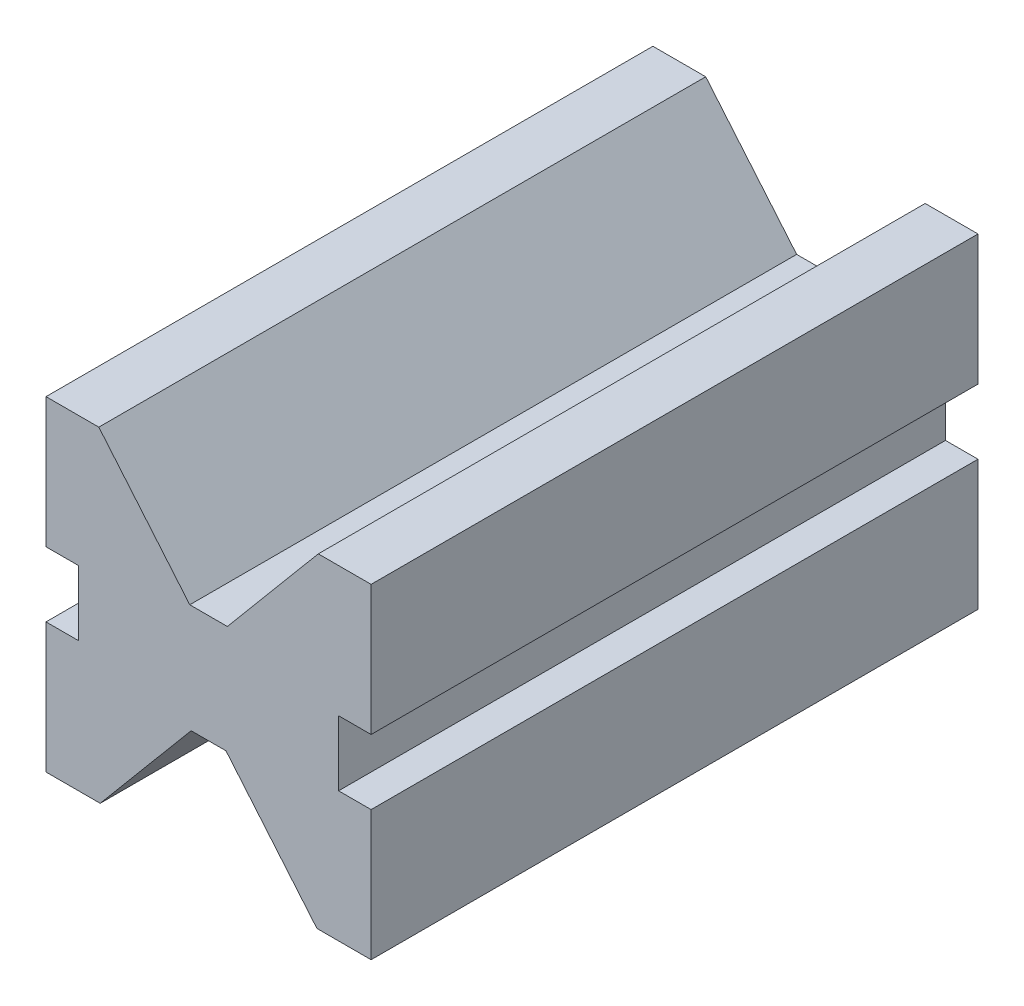
from build123d import *

# Parameters (mm, degrees)
BOSS_EXTRUDE1_DEPTH = 2844.8


with BuildPart() as part:
    # Sketch1 → Boss-Extrude1 (new body)
    with BuildSketch(Plane.XY):
        Polygon((-88.087387362, 254), (88.087387362, 254), (514.35, 762), (762, 762), (762, 152.4), (609.6, 152.4), (609.6, -152.4), (762, -152.4), (762, -762), (508, -762), (81.737387362, -254), (-81.737387362, -254), (-508, -762), (-762, -762), (-762, -152.4), (-609.6, -152.4), (-609.6, 152.4), (-762, 152.4), (-762, 762), (-514.35, 762), align=None)
    extrude(amount=BOSS_EXTRUDE1_DEPTH)


solid = part.part
